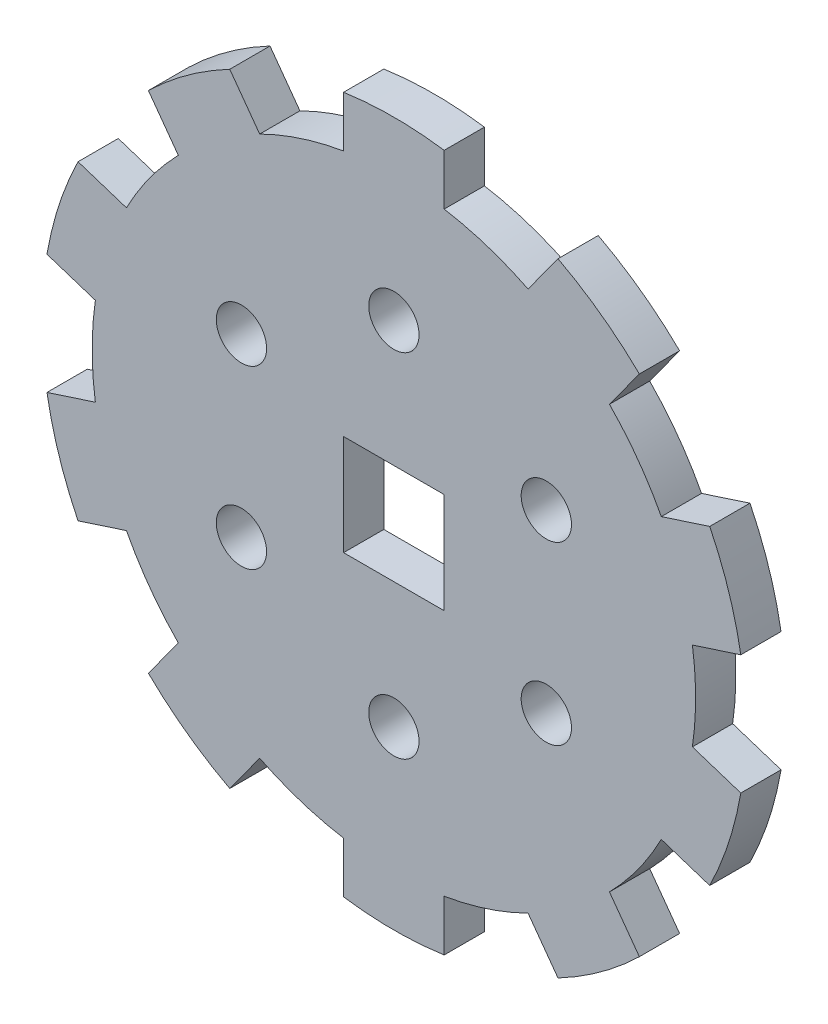
from build123d import *

# Parameters (mm, degrees)
SKETCH1_R           = 2.5
SKETCH1_W           = 10
SKETCH1_H           = 10
BOSS_EXTRUDE1_DEPTH = 4


with BuildPart() as part:
    # Sketch1 → Boss-Extrude1 (new body)
    with BuildSketch(Plane.XY):
        with BuildLine():
            Line((5, 29.580398915), (5, 34.641016151))
            ThreePointArc((5, 34.641016151), (0, 35), (-5, 34.641016151))
            Line((-5, 34.641016151), (-5, 29.580398915))
            ThreePointArc((-5, 29.580398915), (-9.270509831, 28.531695489), (-13.341837268, 26.869971684))
            Line((-13.341837268, 26.869971684), (-16.316393446, 30.96409703))
            ThreePointArc((-16.316393446, 30.96409703), (-20.57248383, 28.315594803), (-24.40656339, 25.086244507))
            Line((-24.40656339, 25.086244507), (-21.432007211, 20.992119162))
            ThreePointArc((-21.432007211, 20.992119162), (-24.270509831, 17.633557569), (-26.587546171, 13.896128547))
            Line((-26.587546171, 13.896128547), (-31.40047917, 15.459945275))
            ThreePointArc((-31.40047917, 15.459945275), (-33.28697807, 10.815594803), (-34.490649114, 5.949380112))
            Line((-34.490649114, 5.949380112), (-29.677716115, 4.385563384))
            ThreePointArc((-29.677716115, 4.385563384), (-30, 0), (-29.677716115, -4.385563384))
            Line((-29.677716115, -4.385563384), (-34.490649114, -5.949380112))
            ThreePointArc((-34.490649114, -5.949380112), (-33.28697807, -10.815594803), (-31.40047917, -15.459945275))
            Line((-31.40047917, -15.459945275), (-26.587546171, -13.896128547))
            ThreePointArc((-26.587546171, -13.896128547), (-24.270509831, -17.633557569), (-21.432007211, -20.992119162))
            Line((-21.432007211, -20.992119162), (-24.40656339, -25.086244507))
            ThreePointArc((-24.40656339, -25.086244507), (-20.57248383, -28.315594803), (-16.316393446, -30.96409703))
            Line((-16.316393446, -30.96409703), (-13.341837268, -26.869971684))
            ThreePointArc((-13.341837268, -26.869971684), (-9.270509831, -28.531695489), (-5, -29.580398915))
            Line((-5, -29.580398915), (-5, -34.641016151))
            ThreePointArc((-5, -34.641016151), (0, -35), (5, -34.641016151))
            Line((5, -34.641016151), (5, -29.580398915))
            ThreePointArc((5, -29.580398915), (9.270509831, -28.531695489), (13.341837268, -26.869971684))
            Line((13.341837268, -26.869971684), (16.316393446, -30.96409703))
            ThreePointArc((16.316393446, -30.96409703), (20.57248383, -28.315594803), (24.40656339, -25.086244507))
            Line((24.40656339, -25.086244507), (21.432007211, -20.992119162))
            ThreePointArc((21.432007211, -20.992119162), (24.270509831, -17.633557569), (26.587546171, -13.896128547))
            Line((26.587546171, -13.896128547), (31.40047917, -15.459945275))
            ThreePointArc((31.40047917, -15.459945275), (33.28697807, -10.815594803), (34.490649114, -5.949380112))
            Line((34.490649114, -5.949380112), (29.677716115, -4.385563384))
            ThreePointArc((29.677716115, -4.385563384), (30, 0), (29.677716115, 4.385563384))
            Line((29.677716115, 4.385563384), (34.490649114, 5.949380112))
            ThreePointArc((34.490649114, 5.949380112), (33.28697807, 10.815594803), (31.40047917, 15.459945275))
            Line((31.40047917, 15.459945275), (26.587546171, 13.896128547))
            ThreePointArc((26.587546171, 13.896128547), (24.270509831, 17.633557569), (21.432007211, 20.992119162))
            Line((21.432007211, 20.992119162), (24.40656339, 25.086244507))
            ThreePointArc((24.40656339, 25.086244507), (20.57248383, 28.315594803), (16.316393446, 30.96409703))
            Line((16.316393446, 30.96409703), (13.341837268, 26.869971684))
            ThreePointArc((13.341837268, 26.869971684), (9.270509831, 28.531695489), (5, 29.580398915))
        make_face()
        with Locations((0, 17.5)):
            Circle(SKETCH1_R, mode=Mode.SUBTRACT)
        with Locations((15.155444566, 8.75)):
            Circle(SKETCH1_R, mode=Mode.SUBTRACT)
        with Locations((15.155444566, -8.75)):
            Circle(SKETCH1_R, mode=Mode.SUBTRACT)
        with Locations((0, -17.5)):
            Circle(SKETCH1_R, mode=Mode.SUBTRACT)
        with Locations((-15.155444566, -8.75)):
            Circle(SKETCH1_R, mode=Mode.SUBTRACT)
        with Locations((-15.155444566, 8.75)):
            Circle(SKETCH1_R, mode=Mode.SUBTRACT)
        Rectangle(SKETCH1_W, SKETCH1_H, mode=Mode.SUBTRACT)
    extrude(amount=BOSS_EXTRUDE1_DEPTH)


solid = part.part
